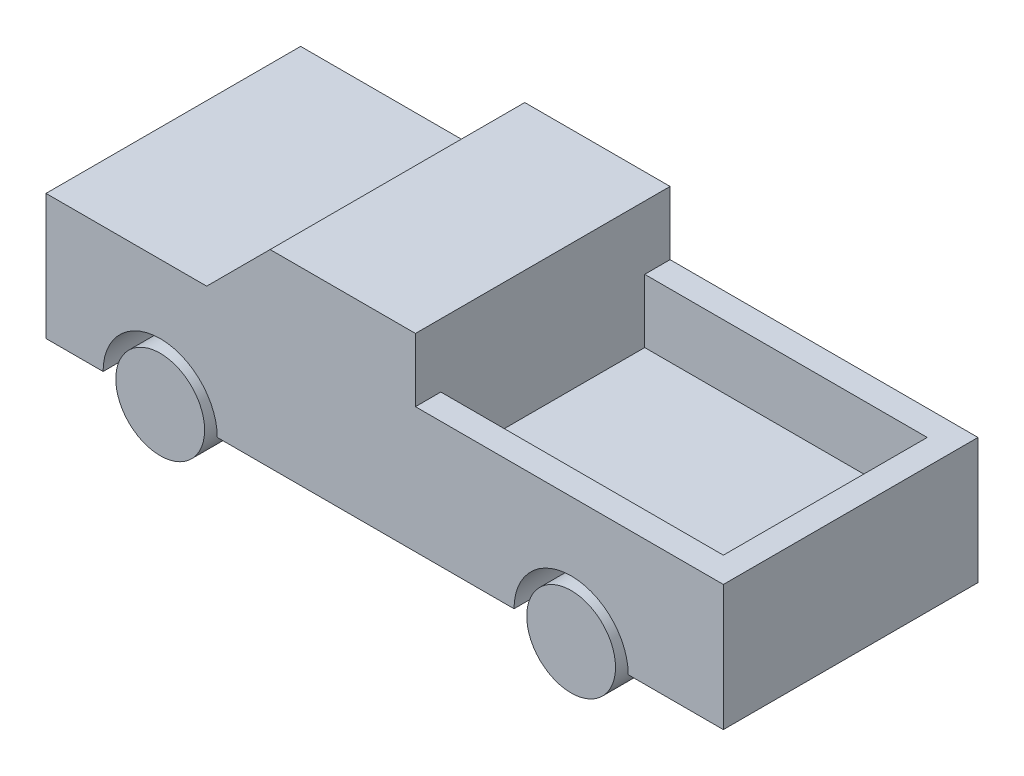
from build123d import *

# Parameters (mm, degrees)
BOSS_EXTRUDE1_DEPTH   = 2007
SKETCH1_R             = 350
BOSS_EXTRUDE1_2_DEPTH = 2007
BOSS_EXTRUDE1_3_DEPTH = 2007
SKETCH2_W             = 2227.003117431
SKETCH2_H             = 1607
CUT_EXTRUDE1_DEPTH    = 500


with BuildPart() as part:
    # Sketch1 → Boss-Extrude1 (new body)
    with BuildSketch(Plane.XY):
        with BuildLine():
            ThreePointArc((4589, -1491), (4139, -1041), (3689, -1491))
            Line((3689, -1491), (1350, -1491))
            ThreePointArc((1350, -1491), (900, -1041), (450, -1491))
            Line((450, -1491), (0, -1491))
            Line((0, -1491), (0, -500))
            Line((0, -500), (1266.50347674, -500))
            Line((1266.50347674, -500), (1766.50347674, 0))
            Line((1766.50347674, 0), (2911.996882569, 0))
            Line((2911.996882569, 0), (2911.996882569, -500))
            Line((2911.996882569, -500), (5339, -500))
            Line((5339, -500), (5339, -1491))
            Line((5339, -1491), (4589, -1491))
        make_face()
    extrude(amount=BOSS_EXTRUDE1_DEPTH)

    # Sketch2 → Cut-Extrude1 (cut)
    with BuildSketch(Plane(origin=(0, -500, 0), x_dir=(1, 0, 0), z_dir=(0, 1, 0))):
        with Locations((4025.498441285, -1003.5)):
            Rectangle(SKETCH2_W, SKETCH2_H)
    extrude(amount=-CUT_EXTRUDE1_DEPTH, mode=Mode.SUBTRACT)


with BuildPart() as body_2:
    # Sketch1 → Boss-Extrude1 2 (new body)
    with BuildSketch(Plane.XY):
        with Locations((900, -1491)):
            Circle(SKETCH1_R)
    extrude(amount=BOSS_EXTRUDE1_2_DEPTH)


with BuildPart() as body_3:
    # Sketch1 → Boss-Extrude1 3 (new body)
    with BuildSketch(Plane.XY):
        with Locations((4139, -1491)):
            Circle(SKETCH1_R)
    extrude(amount=BOSS_EXTRUDE1_3_DEPTH)


solid = Compound([part.part, body_2.part, body_3.part])
